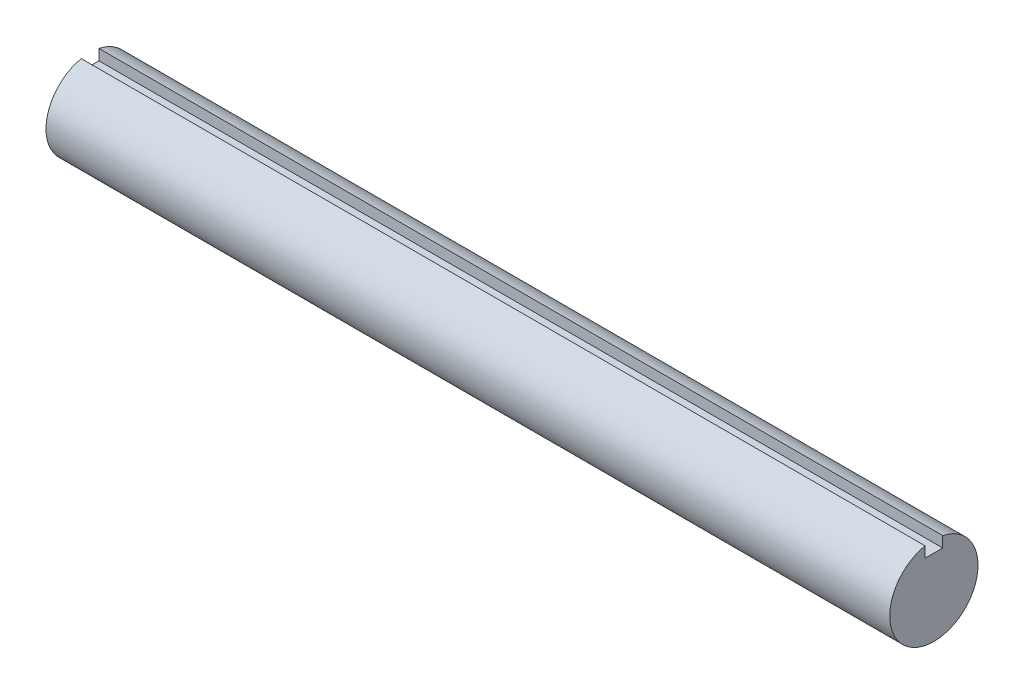
from build123d import *

# Parameters (mm, degrees)
AXLEEXTRUDE_DEPTH = 127


with BuildPart() as part:
    # AxleProfile → AxleExtrude (new body)
    with BuildSketch(Plane(origin=(0, 0, 0), x_dir=(0, 0, -1), z_dir=(1, 0, 0))):
        with BuildLine():
            Line((-1.331, 6.504210944), (-1.331, 4.885210944))
            Line((-1.331, 4.885210944), (1.331, 4.885210944))
            Line((1.331, 4.885210944), (1.331, 6.504210944))
            ThreePointArc((1.331, 6.504210944), (0, -6.639), (-1.331, 6.504210944))
        make_face()
    extrude(amount=AXLEEXTRUDE_DEPTH)


solid = part.part
